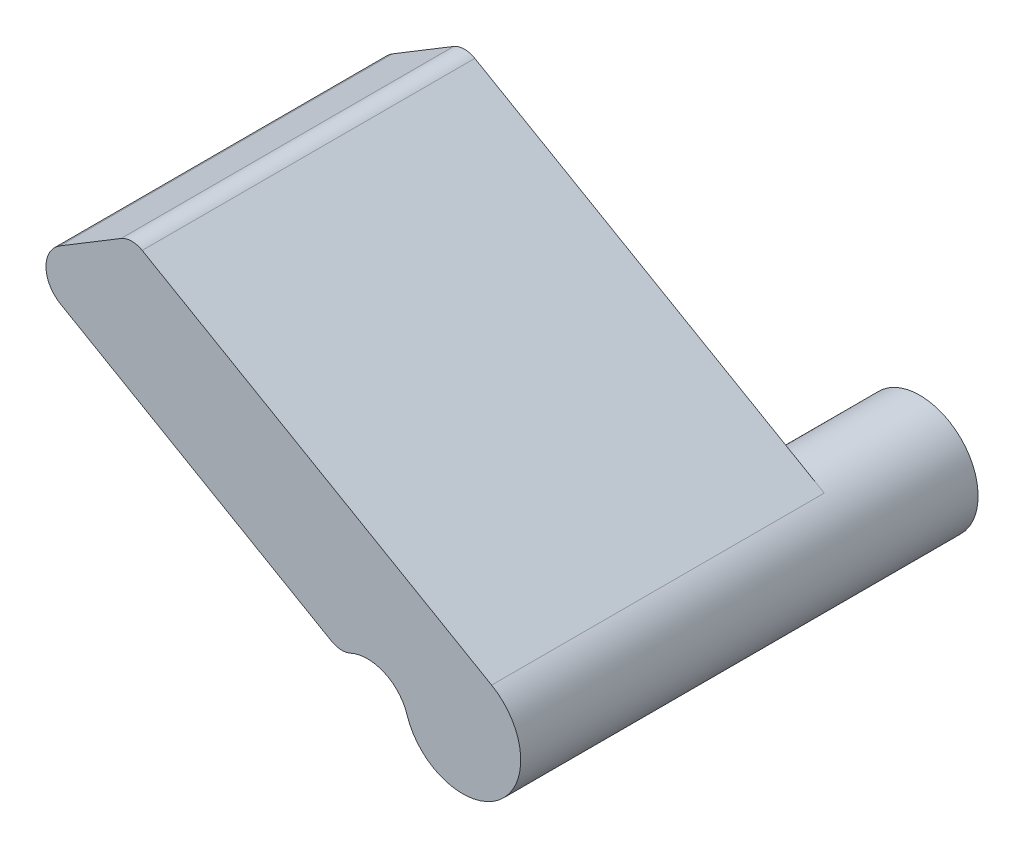
from build123d import *

# Parameters (mm, degrees)
EXTRUDE_1_DEPTH = 8
FILLET_1_R      = 0.5
FILLET_2_R      = 0.7
SKETCH_2_R      = 1.4
EXTRUDE_2_DEPTH = 3


with BuildPart() as part:
    # 草图1 → 凸台-拉伸1 (new body)
    with BuildSketch(Plane.XY):
        with BuildLine():
            Line((0.7, 1.212435565), (-7.960254038, 6.212435565))
            Line((-7.960254038, 6.212435565), (-10.694228634, 4.557735027))
            Line((-10.694228634, 4.557735027), (-2.9, 0.057735027))
            ThreePointArc((-2.9, 0.057735027), (-1.990417738, 0.223935223), (-1.333398647, -0.426670889))
            ThreePointArc((-1.333398647, -0.426670889), (0.878615931, -1.089969746), (0.7, 1.212435565))
        make_face()
    extrude(amount=EXTRUDE_1_DEPTH)

    # 圆角1
    fillet_1_edges = [part.edges().sort_by_distance(p)[0] for p in [
        (-7.960254038, 6.212435565, 4),
        (-2.9, 0.057735027, 4),
    ]]
    fillet(fillet_1_edges, radius=FILLET_1_R)

    # 圆角2
    fillet_2_edges = [part.edges().sort_by_distance(p)[0] for p in [
        (-10.694228634, 4.557735027, 4),
    ]]
    fillet(fillet_2_edges, radius=FILLET_2_R)

    # 草图2 → 凸台-拉伸2 (add)
    with BuildSketch(Plane(origin=(0, 0, 0), x_dir=(-1, 0, 0), z_dir=(0, 0, -1))):
        Circle(SKETCH_2_R)
    extrude(amount=EXTRUDE_2_DEPTH)


solid = part.part
